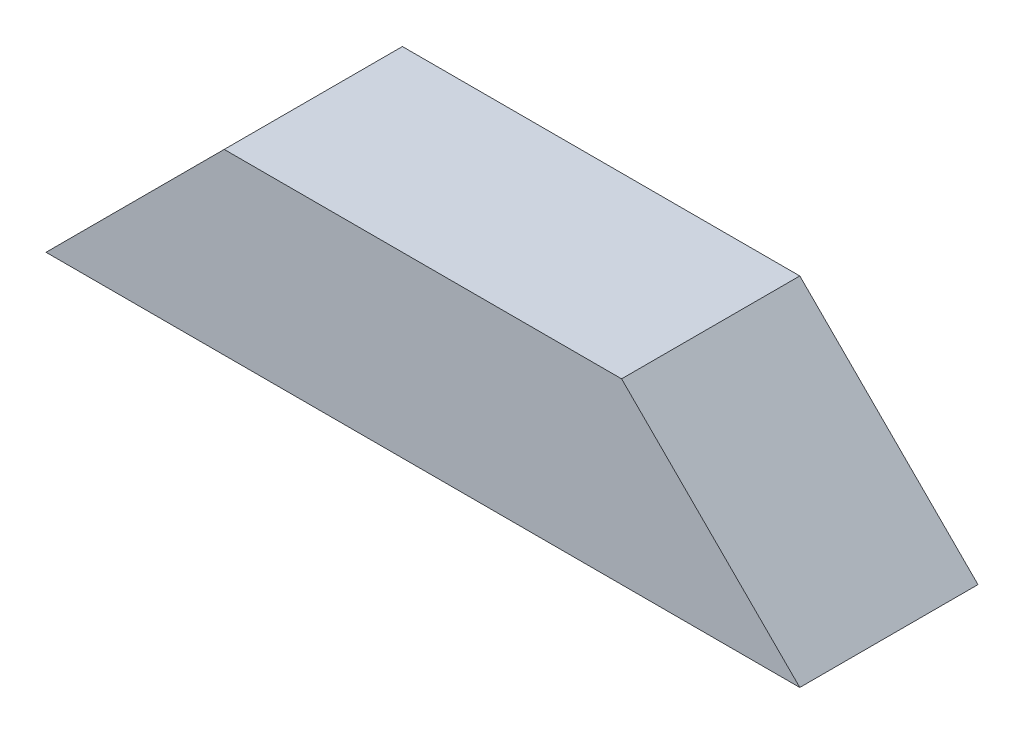
from build123d import *

# Parameters (mm, degrees)
EXTRUDE_1_DEPTH = 10


with BuildPart() as part:
    # 草图1 → 凸台-拉伸1 (new body)
    with BuildSketch(Plane.XY):
        Polygon((38.343533802, 49.922103819), (80.643533802, 49.922103819), (70.643533802, 59.922103819), (48.343533802, 59.922103819), align=None)
    extrude(amount=EXTRUDE_1_DEPTH)


solid = part.part
